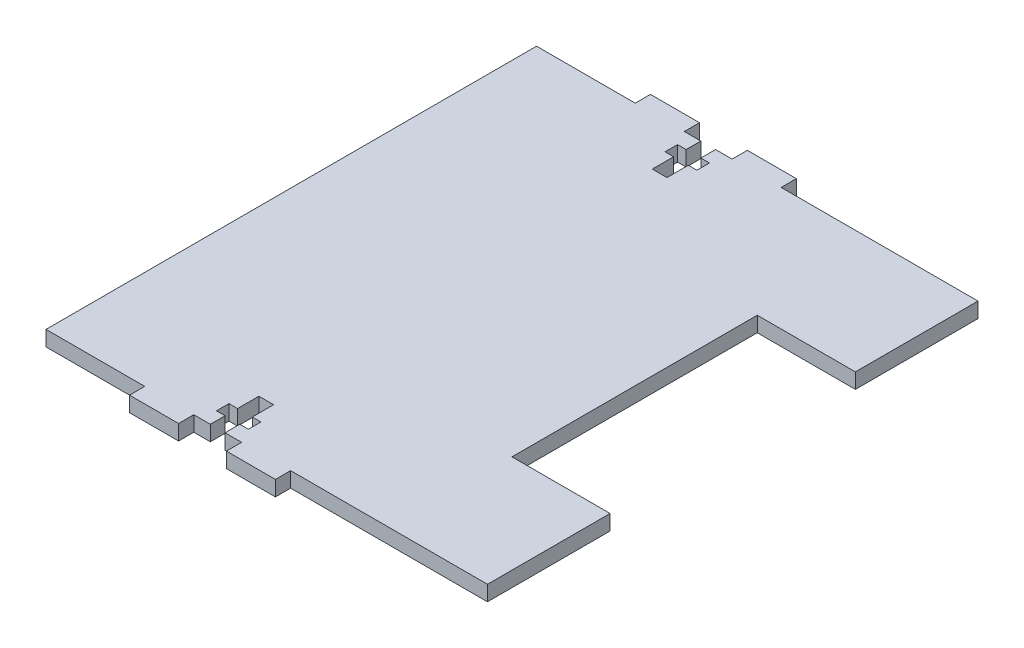
from build123d import *

# Parameters (mm, degrees)
SKETCH_1_W      = 10
SKETCH_1_H      = 3.1
EXTRUDE_1_DEPTH = 3.1
SKETCH_2_W      = 20
SKETCH_2_H      = 25
EXTRUDE_2_DEPTH = 3.1


with BuildPart() as part:
    # 草图1 → 凸台-拉伸1 (new body)
    with BuildSketch(Plane(origin=(0, 0, 0), x_dir=(1, 0, 0), z_dir=(0, 1, 0))):
        Polygon((-35, 50), (-35, -50), (-14.875, -50), (-4.875, -50), (-1.5, -50), (-1.5, -47), (-3.25, -47), (-3.25, -44.45), (-1.5, -44.45), (-1.5, -40.1), (1.5, -40.1), (1.5, -44.45), (3.25, -44.45), (3.25, -47), (1.5, -47), (1.5, -50), (4.875, -50), (14.875, -50), (35, -50), (35, 50), (14.875, 50), (4.875, 50), (1.5, 50), (1.5, 47), (3.25, 47), (3.25, 44.45), (1.5, 44.45), (1.5, 40.1), (-1.5, 40.1), (-1.5, 44.45), (-3.25, 44.45), (-3.25, 47), (-1.5, 47), (-1.5, 50), (-4.875, 50), (-14.875, 50), align=None)
        with Locations((-9.875, 51.55)):
            Rectangle(SKETCH_1_W, SKETCH_1_H)
        with Locations((9.875, 51.55)):
            Rectangle(SKETCH_1_W, SKETCH_1_H)
        with Locations((-9.875, -51.55)):
            Rectangle(SKETCH_1_W, SKETCH_1_H)
        with Locations((9.875, -51.55)):
            Rectangle(SKETCH_1_W, SKETCH_1_H)
    extrude(amount=EXTRUDE_1_DEPTH)

    # 草图2 → 凸台-拉伸2 (add)
    with BuildSketch(Plane(origin=(0, 0, 0), x_dir=(1, 0, 0), z_dir=(0, 1, 0))):
        with Locations((45, 37.5)):
            Rectangle(SKETCH_2_W, SKETCH_2_H)
        with Locations((45, -37.5)):
            Rectangle(SKETCH_2_W, SKETCH_2_H)
    extrude(amount=EXTRUDE_2_DEPTH)


solid = part.part
